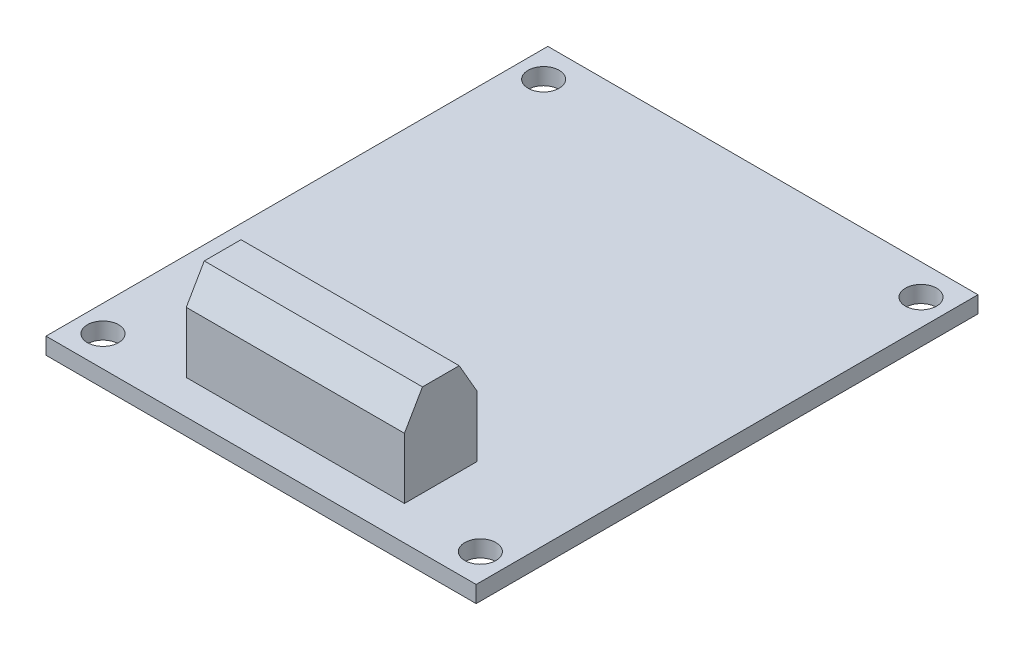
from build123d import *

# Parameters (mm, degrees)
SKETCH1_W             = 41.4
SKETCH1_H             = 48.3
SKETCH1_R             = 1.5
BOSS_EXTRUDE1_DEPTH   = 1.6
SKETCH2_W             = 21
SKETCH2_H             = 7
BOSS_EXTRUDE2_DEPTH   = 8.85
CHAMFER1_SIZE         = 3
CHAMFER1_SIZE2        = 1.732050808
CHAMFER1_PART_2_SIZE  = 3
CHAMFER1_PART_2_SIZE2 = 1.732050808


with BuildPart() as part:
    # Sketch1 → Boss-Extrude1 (new body)
    with BuildSketch(Plane(origin=(0, 0, 0), x_dir=(1, 0, 0), z_dir=(0, 1, 0))):
        Rectangle(SKETCH1_W, SKETCH1_H)
        with Locations((-18.16, 21.205)):
            Circle(SKETCH1_R, mode=Mode.SUBTRACT)
        with Locations((18.16, 21.205)):
            Circle(SKETCH1_R, mode=Mode.SUBTRACT)
        with Locations((18.16, -21.205)):
            Circle(SKETCH1_R, mode=Mode.SUBTRACT)
        with Locations((-18.16, -21.205)):
            Circle(SKETCH1_R, mode=Mode.SUBTRACT)
    extrude(amount=BOSS_EXTRUDE1_DEPTH)

    # Sketch2 → Boss-Extrude2 (add)
    with BuildSketch(Plane(origin=(0, 1.6, 0), x_dir=(1, 0, 0), z_dir=(0, 1, 0))):
        with Locations((0, -17.35)):
            Rectangle(SKETCH2_W, SKETCH2_H)
    extrude(amount=BOSS_EXTRUDE2_DEPTH)

    # Chamfer1
    chamfer1_edges = [part.edges().sort_by_distance(p)[0] for p in [
        (0, 10.45, 13.85),
    ]]
    chamfer1_side = [part.faces().sort_by_distance(p)[0] for p in [
        (0, 6.025, 13.85),
    ]]
    chamfer(chamfer1_edges, length=CHAMFER1_SIZE, length2=CHAMFER1_SIZE2, reference=chamfer1_side[0])

    # Chamfer1 part 2
    chamfer1_part_2_edges = [part.edges().sort_by_distance(p)[0] for p in [
        (0, 10.45, 20.85),
    ]]
    chamfer1_part_2_side = [part.faces().sort_by_distance(p)[0] for p in [
        (0, 6.025, 20.85),
    ]]
    chamfer(chamfer1_part_2_edges, length=CHAMFER1_PART_2_SIZE, length2=CHAMFER1_PART_2_SIZE2, reference=chamfer1_part_2_side[0])


solid = part.part
